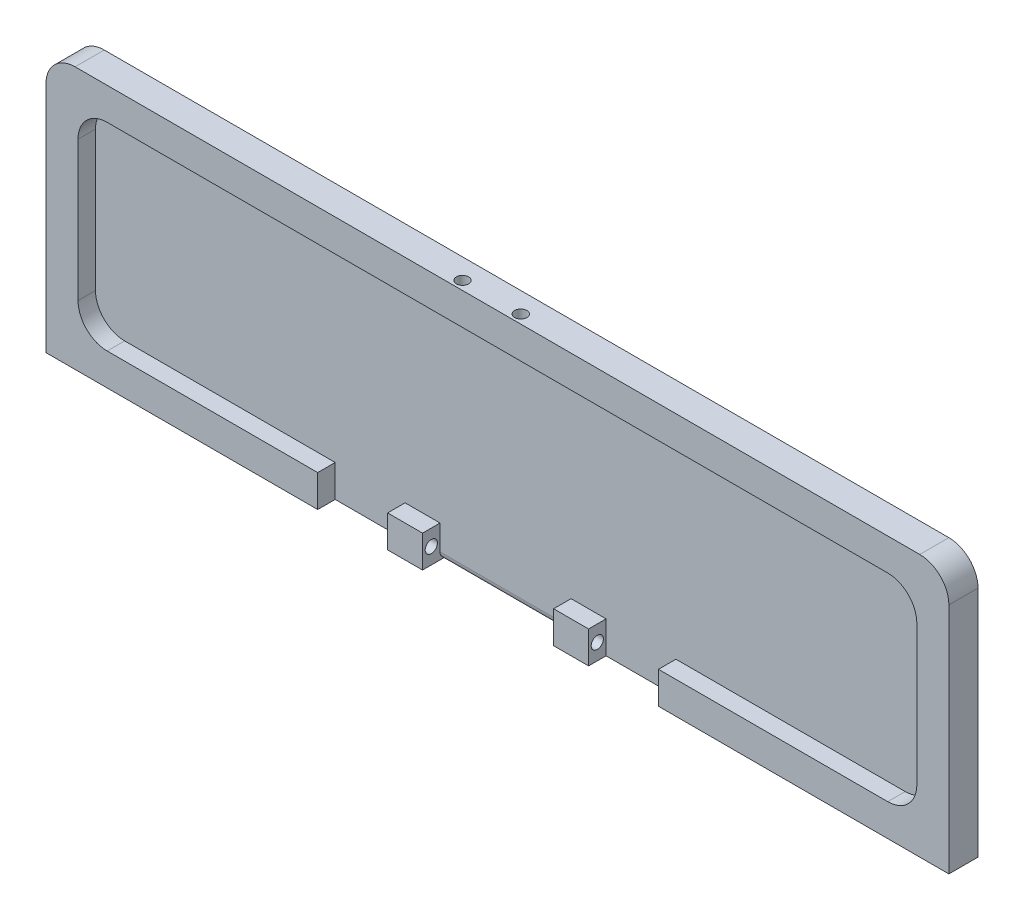
from build123d import *

# Parameters (mm, degrees)
SKETCH_1_W                  = 155
SKETCH_1_H                  = 45
EXTRUDE_1_DEPTH             = 5
SKETCH_2_W                  = 144
SKETCH_2_H                  = 34
CUT_EXTRUDE_1_DEPTH         = 3
FILLET_1_R                  = 5
FILLET_2_R                  = 5
SKETCH_7_W                  = 22.5
SKETCH_7_H                  = 5.5
CUT_EXTRUDE_2_DEPTH         = 3
FILLET_7_R                  = 1.2
SKETCH_9_W                  = 12
SKETCH_9_H                  = 5.5
CUT_EXTRUDE_3_DEPTH         = 3
HOLE_WIZARD_2_1_2_1_2_D     = 2.1
HOLE_WIZARD_2_1_2_1_2_DEPTH = 13.2
HOLE_WIZARD_2_1_2_1_2_TIP   = 0.63090365
SKETCH_15_W                 = 12
SKETCH_15_H                 = 5.5
CUT_EXTRUDE_4_DEPTH         = 3


with BuildPart() as part:
    # 草图1 → 凸台-拉伸1 (new body)
    with BuildSketch(Plane.XY):
        Rectangle(SKETCH_1_W, SKETCH_1_H)
    extrude(amount=EXTRUDE_1_DEPTH)

    # 草图2 → 切除-拉伸1 (cut)
    with BuildSketch(Plane.XY.offset(5)):
        Rectangle(SKETCH_2_W, SKETCH_2_H)
    extrude(amount=-CUT_EXTRUDE_1_DEPTH, mode=Mode.SUBTRACT)

    # 圆角1
    fillet_1_edges = [part.edges().sort_by_distance(p)[0] for p in [
        (-77.5, 22.5, 2.5),
        (77.5, 22.5, 2.5),
    ]]
    fillet(fillet_1_edges, radius=FILLET_1_R)

    # 圆角2
    fillet_2_edges = [part.edges().sort_by_distance(p)[0] for p in [
        (-72, -17, 3.5),
        (-72, 17, 3.5),
        (72, 17, 3.5),
        (72, -17, 3.5),
    ]]
    fillet(fillet_2_edges, radius=FILLET_2_R)

    # 草图7 → 切除-拉伸2 (cut)
    with BuildSketch(Plane.XY.offset(5)):
        with Locations((-1.604272417, -19.75)):
            Rectangle(SKETCH_7_W, SKETCH_7_H)
    extrude(amount=-CUT_EXTRUDE_2_DEPTH, mode=Mode.SUBTRACT)

    # 圆角7
    fillet_7_edges = [part.edges().sort_by_distance(p)[0] for p in [
        (-1.604272417, -22.5, 2),
    ]]
    fillet(fillet_7_edges, radius=FILLET_7_R)

    # 草图9 → 切除-拉伸3 (cut)
    with BuildSketch(Plane.XY.offset(5)):
        with Locations((21.645727583, -19.75)):
            Rectangle(SKETCH_9_W, SKETCH_9_H)
    extrude(amount=-CUT_EXTRUDE_3_DEPTH, mode=Mode.SUBTRACT)

    # 草图11 → Ø2.1 (2.1) 直径孔1 (revolve, cut)
    with BuildSketch(Plane(origin=(15.645727583, -19.75, 3.5), x_dir=(0, 0, -1), z_dir=(0, 1, 0))):
        Polygon((0, 0), (0, 36.63090365), (1.05, 36), (1.05, 0), align=None)
    revolve(axis=Axis((21.995727583, -19.75, 3.5), (-1, 0, 0)), mode=Mode.SUBTRACT)

    # Ø2.1 (2.1) 直径孔2
    with Locations(Plane(origin=(0, 22.5, 0), x_dir=(1, 0, 0), z_dir=(0, 1, 0))):
        with Locations((2.5, -3.5), (-7.5, -3.5)):
            Hole(HOLE_WIZARD_2_1_2_1_2_D / 2, depth=HOLE_WIZARD_2_1_2_1_2_DEPTH)
            with Locations((0, 0, -(HOLE_WIZARD_2_1_2_1_2_DEPTH + HOLE_WIZARD_2_1_2_1_2_TIP / 2))):  # 118° drill point
                Cone(0, HOLE_WIZARD_2_1_2_1_2_D / 2, HOLE_WIZARD_2_1_2_1_2_TIP, mode=Mode.SUBTRACT)

    # 草图15 → 切除-拉伸4 (cut)
    with BuildSketch(Plane.XY.offset(5)):
        with Locations((-24.854272417, -19.75)):
            Rectangle(SKETCH_15_W, SKETCH_15_H)
    extrude(amount=-CUT_EXTRUDE_4_DEPTH, mode=Mode.SUBTRACT)


solid = part.part
